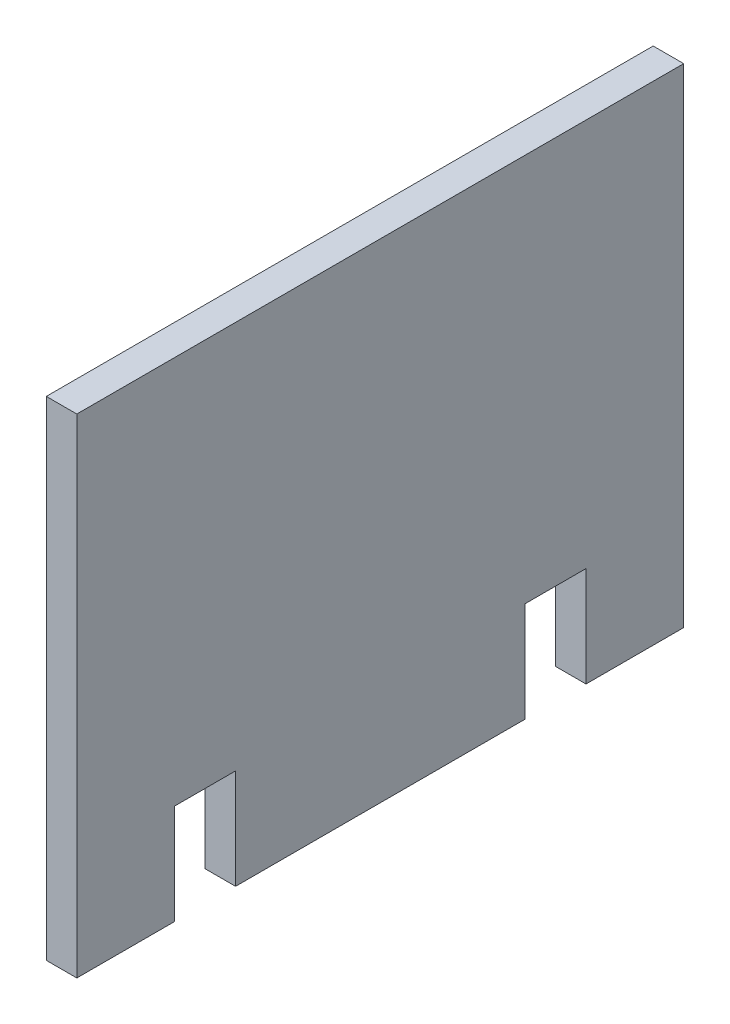
from build123d import *

# Parameters (mm, degrees)
SKETCH1_W           = 63.12
SKETCH1_H           = 50.8
BOSS_EXTRUDE1_DEPTH = 3.175
SKETCH2_W           = 6.35
SKETCH2_H           = 10.4
CUT_EXTRUDE1_DEPTH  = 4.175


with BuildPart() as part:
    # Sketch1 → Boss-Extrude1 (new body)
    with BuildSketch(Plane(origin=(0, 0, 0), x_dir=(0, 0, -1), z_dir=(1, 0, 0))):
        with Locations((31.56, 25.4)):
            Rectangle(SKETCH1_W, SKETCH1_H)
    extrude(amount=BOSS_EXTRUDE1_DEPTH)

    # Sketch2 → Cut-Extrude1 (cut, through all)
    with BuildSketch(Plane(origin=(3.175, 0, 0), x_dir=(0, 0, -1), z_dir=(1, 0, 0))):
        with Locations((13.335, 5.2)):
            Rectangle(SKETCH2_W, SKETCH2_H)
        with Locations((49.785, 5.2)):
            Rectangle(SKETCH2_W, SKETCH2_H)
    extrude(amount=-CUT_EXTRUDE1_DEPTH, mode=Mode.SUBTRACT)


solid = part.part
